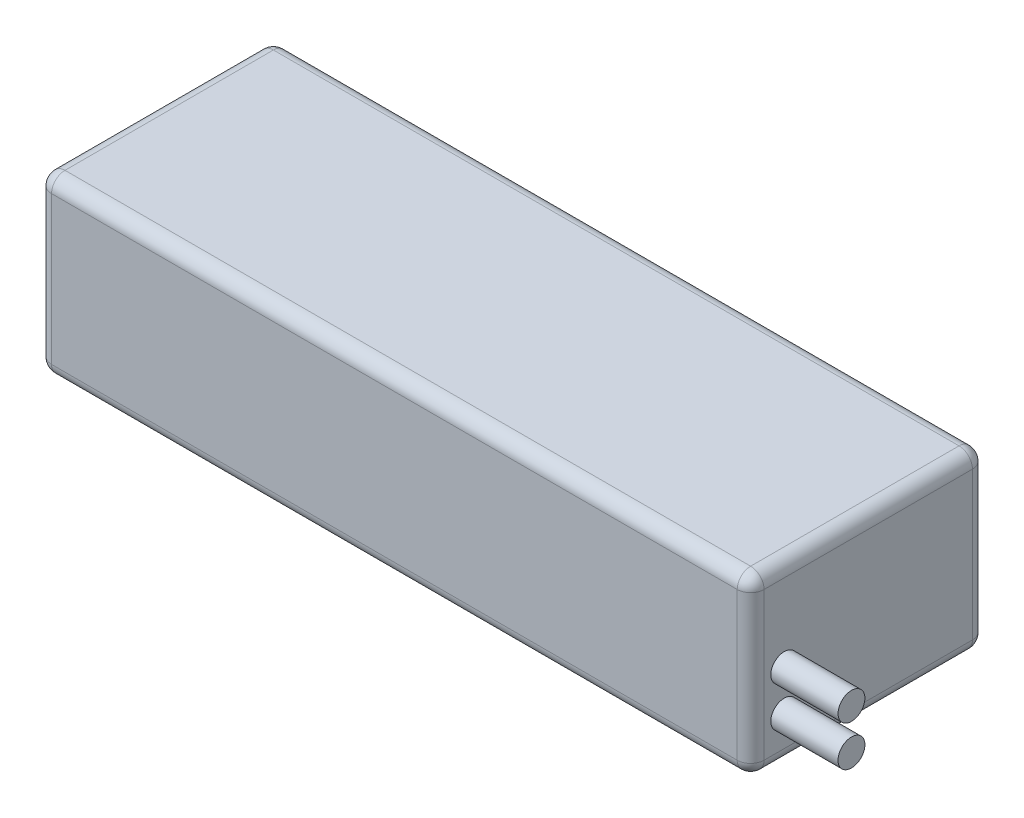
from build123d import *

# Parameters (mm, degrees)
SKETCH1_W           = 106
SKETCH1_H           = 35
BOSS_EXTRUDE1_DEPTH = 26
FILLET1_R           = 2
SKETCH2_R           = 2
BOSS_EXTRUDE2_DEPTH = 10


with BuildPart() as part:
    # Sketch1 → Boss-Extrude1 (new body)
    with BuildSketch(Plane(origin=(0, 0, 0), x_dir=(1, 0, 0), z_dir=(0, 1, 0))):
        Rectangle(SKETCH1_W, SKETCH1_H)
    extrude(amount=BOSS_EXTRUDE1_DEPTH)

    # Fillet1
    fillet1_edges = [part.edges().sort_by_distance(p)[0] for p in [
        (-53, 26, 0),
        (0, 26, 17.5),
        (53, 26, 0),
        (0, 0, 17.5),
        (-53, 0, 0),
        (0, 0, -17.5),
        (53, 0, 0),
        (53, 13, 17.5),
        (-53, 13, 17.5),
        (-53, 13, -17.5),
        (53, 13, -17.5),
        (0, 26, -17.5),
    ]]
    fillet(fillet1_edges, radius=FILLET1_R)

    # Sketch2 → Boss-Extrude2 (add)
    with BuildSketch(Plane(origin=(53, 0, 0), x_dir=(0, 0, -1), z_dir=(1, 0, 0))):
        with Locations((-12.5, 6.5)):
            Circle(SKETCH2_R)
        with Locations((-12.5, 12.5)):
            Circle(SKETCH2_R)
    extrude(amount=BOSS_EXTRUDE2_DEPTH)


solid = part.part
